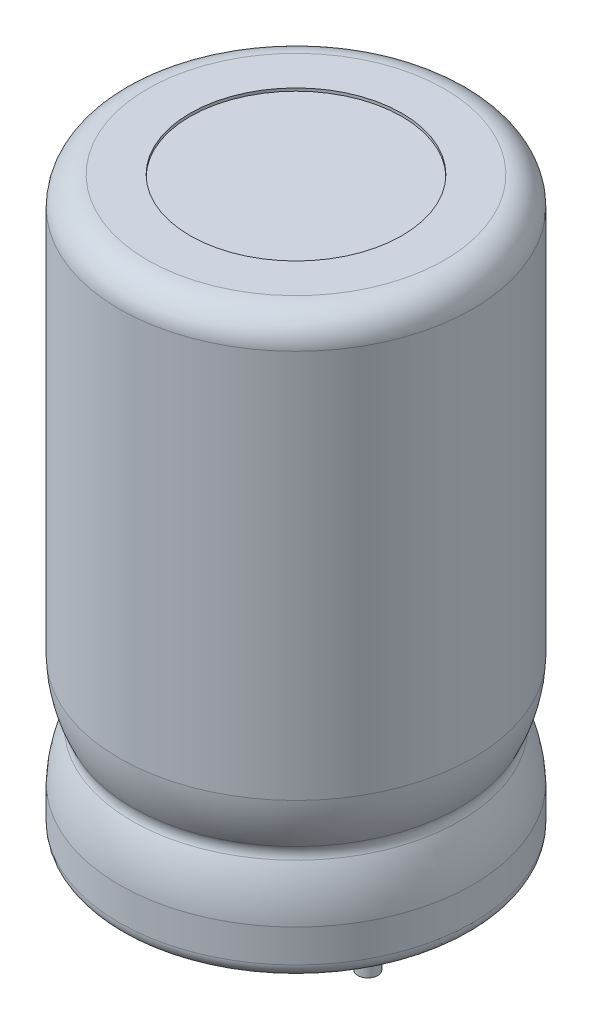
from build123d import *

# Parameters (mm, degrees)
SKETCH2_R                = 0.35
BASE_EXTRUDE_DEPTH       = 3
SKETCH3_R                = 3.75
BOSS_EXTRUDE1_DEPTH      = 0.5
SKETCH4_R                = 0.35
BOSS_EXTRUDE2_DEPTH      = 3
SKETCH5_R                = 6.25
BOSS_EXTRUDE4_DEPTH      = 0.1
BOSS_EXTRUDE4_DEPTH_BACK = 20.2
SKETCH7_R                = 3.75
SKETCH7_R_2              = 0.35
CUT_EXTRUDE3_DEPTH       = 0.1
FILLET1_R                = 0.5
FILLET2_R                = 1
SKETCH8_R                = 3.75
CUT_EXTRUDE4_DEPTH       = 0.1


with BuildPart() as part:
    # Sketch2 → Base-Extrude (new body)
    with BuildSketch(Plane(origin=(0, 0, 0), x_dir=(1, 0, 0), z_dir=(0, 1, 0))):
        Circle(SKETCH2_R)
    extrude(amount=-BASE_EXTRUDE_DEPTH)

    # Sketch3 → Boss-Extrude1 (add)
    with BuildSketch(Plane(origin=(0, 0, 0), x_dir=(-1, 0, 0), z_dir=(0, 1, 0))):
        with Locations((2.54, 0)):
            Circle(SKETCH3_R)
    extrude(amount=BOSS_EXTRUDE1_DEPTH)

    # Sketch4 → Boss-Extrude2 (add)
    with BuildSketch(Plane.XZ):
        with Locations((-5.08, 0)):
            Circle(SKETCH4_R)
    extrude(amount=BOSS_EXTRUDE2_DEPTH)

    # Sketch5 → Boss-Extrude4 (add, two sides)
    with BuildSketch(Plane.XZ.offset(0.1)) as boss_extrude4_sk:
        with Locations((-2.54, 0)):
            Circle(SKETCH5_R)
    extrude(amount=BOSS_EXTRUDE4_DEPTH)
    extrude(boss_extrude4_sk.sketch, amount=-BOSS_EXTRUDE4_DEPTH_BACK)

    # Sketch7 → Cut-Extrude3 (cut)
    with BuildSketch(Plane.XZ.offset(0.2)):
        with Locations((-2.54, 0)):
            Circle(SKETCH7_R)
        with Locations((-5.08, 0)):
            Circle(SKETCH7_R_2, mode=Mode.SUBTRACT)
        Circle(SKETCH7_R_2, mode=Mode.SUBTRACT)
    extrude(amount=-CUT_EXTRUDE3_DEPTH, mode=Mode.SUBTRACT)

    # Fillet1
    fillet1_edges = [part.edges().sort_by_distance(p)[0] for p in [
        (-8.79, -0.2, 0),
    ]]
    fillet(fillet1_edges, radius=FILLET1_R)

    # Fillet2
    fillet2_edges = [part.edges().sort_by_distance(p)[0] for p in [
        (-8.79, 20.1, 0),
    ]]
    fillet(fillet2_edges, radius=FILLET2_R)

    # Sketch8 → Cut-Extrude4 (cut)
    with BuildSketch(Plane(origin=(0, 20.1, 0), x_dir=(-1, 0, 0), z_dir=(0, 1, 0))):
        with Locations((2.54, 0)):
            Circle(SKETCH8_R)
    extrude(amount=-CUT_EXTRUDE4_DEPTH, mode=Mode.SUBTRACT)

    # Sketch10 → Cut-Revolve1 (revolve, cut)
    with BuildSketch(Plane.XY):
        with BuildLine():
            Line((3.71, 5.69), (4.21, 5.69))
            Line((4.21, 5.69), (4.21, 1.11))
            Line((4.21, 1.11), (3.71, 1.11))
            ThreePointArc((3.71, 1.11), (3.618018735, 2.178778092), (3.26, 3.19))
            ThreePointArc((3.26, 3.19), (3.21, 3.4), (3.26, 3.61))
            ThreePointArc((3.26, 3.61), (3.618018735, 4.621221908), (3.71, 5.69))
        make_face()
    revolve(axis=Axis((-2.54, 0.346345216, 0), (0, 1, 0)), mode=Mode.SUBTRACT)


solid = part.part
